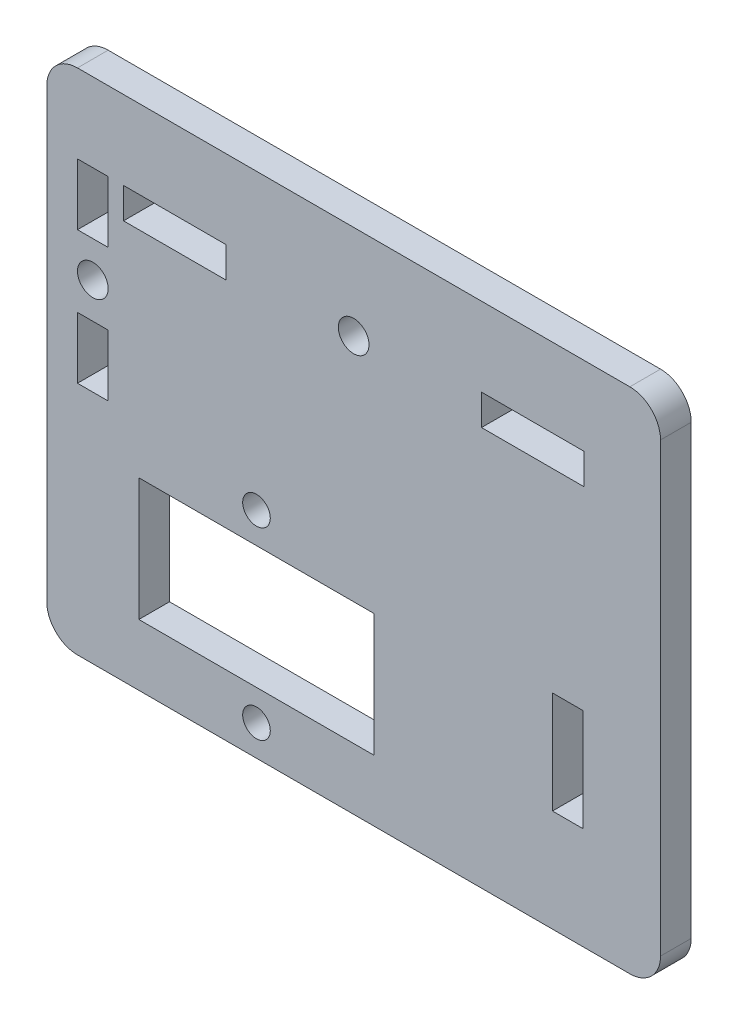
from build123d import *

# Parameters (mm, degrees)
MODEL_R             = 1.500000002
MODEL_R_2           = 1.35
MODEL_R_3           = 1.500000003
MODEL_W             = 3
MODEL_H             = 10
BOSS_EXTRUDE1_DEPTH = 3


with BuildPart() as part:
    # Model → Boss-Extrude1 (new body)
    with BuildSketch(Plane.XY):
        with BuildLine():
            Line((77.350374728, 38.932799758), (77.3504385, 61.847914879))
            ThreePointArc((77.3504385, 61.847914879), (76.471798677, 63.969197152), (74.350545547, 64.84790733))
            Line((74.350545547, 64.84790733), (73.850545547, 64.84790733))
            Line((73.850545547, 64.84790733), (20.350545547, 64.848184253))
            ThreePointArc((20.350545547, 64.848184253), (18.229231749, 63.96968584), (17.350530152, 61.848456197))
            Line((17.350530152, 61.848456197), (17.350325984, 19.035510771))
            Line((17.350325984, 19.035510771), (17.350321434, 18.148199638))
            ThreePointArc((17.350321434, 18.148199638), (18.228860554, 16.026745133), (20.350306049, 15.148184254))
            Line((20.350306049, 15.148184254), (32.850606049, 15.14812015))
            Line((32.850606049, 15.14812015), (74.350306048, 15.147907331))
            ThreePointArc((74.350306048, 15.147907331), (76.471660555, 16.026546451), (77.350321433, 18.147891946))
            Line((77.350321433, 18.147891946), (77.350374728, 38.932799758))
        make_face()
        with Locations((47.350513739, 55.648045793)):
            Circle(MODEL_R, mode=Mode.SUBTRACT)
        with Locations((37.850318867, 18.148094512)):
            Circle(MODEL_R_2, mode=Mode.SUBTRACT)
        with Locations((37.850416303, 36.148094512)):
            Circle(MODEL_R_2, mode=Mode.SUBTRACT)
        with Locations((21.850472716, 47.648176561)):
            Circle(MODEL_R_3, mode=Mode.SUBTRACT)
        Polygon((23.350454767, 44.148168869), (23.350423998, 38.148168869), (20.350423998, 38.148184254), (20.350454767, 44.148184254), align=None, mode=Mode.SUBTRACT)
        Polygon((23.350521434, 57.148168869), (23.350490665, 51.148168869), (20.350490665, 51.148184253), (20.350521434, 57.148184253), align=None, mode=Mode.SUBTRACT)
        Polygon((49.350336818, 21.148035536), (49.350398356, 33.148035536), (26.350398357, 33.148153484), (26.350336818, 21.148153485), align=None, mode=Mode.SUBTRACT)
        Polygon((34.850506049, 54.148109894), (34.850521434, 57.148109894), (24.850521434, 57.148161176), (24.850506049, 54.148161176), align=None, mode=Mode.SUBTRACT)
        Polygon((69.850505905, 54.147930167), (69.850521433, 57.147930167), (59.850505905, 57.147981929), (59.850505905, 54.147930167), align=None, mode=Mode.SUBTRACT)
        with Locations((68.28527947, 30.147930167)):
            Rectangle(MODEL_W, MODEL_H, mode=Mode.SUBTRACT)
    extrude(amount=BOSS_EXTRUDE1_DEPTH)


solid = part.part
